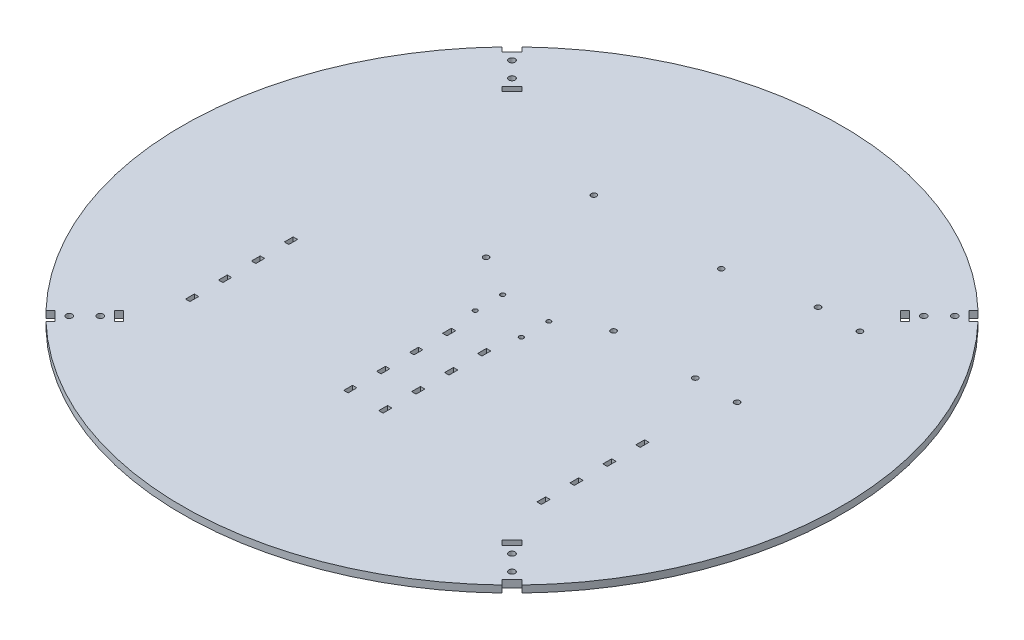
from build123d import *

# Parameters (mm, degrees)
SKETCH1_R           = 150
SKETCH1_R_2         = 1.25
SKETCH1_R_3         = 1
SKETCH1_W           = 2
SKETCH1_H           = 4
BOSS_EXTRUDE1_DEPTH = 3.175
SKETCH2_R           = 1.4224
CUT_EXTRUDE1_DEPTH  = 10


with BuildPart() as part:
    # Sketch1 → Boss-Extrude1 (new body)
    with BuildSketch(Plane(origin=(0, 0, 0), x_dir=(1, 0, 0), z_dir=(0, 1, 0))):
        with Locations((106.066017178, 106.066017178)):
            Circle(SKETCH1_R)
        with Locations((77.066017178, 172.293864025)):
            Circle(SKETCH1_R_2, mode=Mode.SUBTRACT)
        with Locations((135.066017178, 172.293864025)):
            Circle(SKETCH1_R_2, mode=Mode.SUBTRACT)
        with Locations((77.066017178, 123.293864025)):
            Circle(SKETCH1_R_2, mode=Mode.SUBTRACT)
        with Locations((135.066017178, 123.293864025)):
            Circle(SKETCH1_R_2, mode=Mode.SUBTRACT)
        with Locations((95.566017178, 112.316017178)):
            Circle(SKETCH1_R_3, mode=Mode.SUBTRACT)
        with Locations((116.566017178, 112.316017178)):
            Circle(SKETCH1_R_3, mode=Mode.SUBTRACT)
        with Locations((116.566017178, 99.816017178)):
            Circle(SKETCH1_R_3, mode=Mode.SUBTRACT)
        with Locations((95.566017178, 99.816017178)):
            Circle(SKETCH1_R_3, mode=Mode.SUBTRACT)
        with Locations((172.245046965, 123.293864025)):
            Circle(SKETCH1_R_2, mode=Mode.SUBTRACT)
        with Locations((172.245046965, 179.173864025)):
            Circle(SKETCH1_R_2, mode=Mode.SUBTRACT)
        with Locations((191.295046965, 123.293864025)):
            Circle(SKETCH1_R_2, mode=Mode.SUBTRACT)
        with Locations((191.295046965, 179.173864025)):
            Circle(SKETCH1_R_2, mode=Mode.SUBTRACT)
        with Locations((98.098528615, 85.439926251)):
            Rectangle(SKETCH1_W, SKETCH1_H, mode=Mode.SUBTRACT)
        with Locations((26.098528615, 85.439926251)):
            Rectangle(SKETCH1_W, SKETCH1_H, mode=Mode.SUBTRACT)
        with Locations((98.098528615, 70.439926251)):
            Rectangle(SKETCH1_W, SKETCH1_H, mode=Mode.SUBTRACT)
        with Locations((98.098528615, 55.439926251)):
            Rectangle(SKETCH1_W, SKETCH1_H, mode=Mode.SUBTRACT)
        with Locations((98.098528615, 40.439926251)):
            Rectangle(SKETCH1_W, SKETCH1_H, mode=Mode.SUBTRACT)
        with Locations((26.098528615, 70.439926251)):
            Rectangle(SKETCH1_W, SKETCH1_H, mode=Mode.SUBTRACT)
        with Locations((26.098528615, 55.439926251)):
            Rectangle(SKETCH1_W, SKETCH1_H, mode=Mode.SUBTRACT)
        with Locations((26.098528615, 40.439926251)):
            Rectangle(SKETCH1_W, SKETCH1_H, mode=Mode.SUBTRACT)
        with Locations((114.033505741, 85.439926251)):
            Rectangle(SKETCH1_W, SKETCH1_H, mode=Mode.SUBTRACT)
        with Locations((114.033505741, 70.439926251)):
            Rectangle(SKETCH1_W, SKETCH1_H, mode=Mode.SUBTRACT)
        with Locations((114.033505741, 55.439926251)):
            Rectangle(SKETCH1_W, SKETCH1_H, mode=Mode.SUBTRACT)
        with Locations((114.033505741, 40.439926251)):
            Rectangle(SKETCH1_W, SKETCH1_H, mode=Mode.SUBTRACT)
        with Locations((186.033505741, 40.439926251)):
            Rectangle(SKETCH1_W, SKETCH1_H, mode=Mode.SUBTRACT)
        with Locations((186.033505741, 55.439926251)):
            Rectangle(SKETCH1_W, SKETCH1_H, mode=Mode.SUBTRACT)
        with Locations((186.033505741, 70.439926251)):
            Rectangle(SKETCH1_W, SKETCH1_H, mode=Mode.SUBTRACT)
        with Locations((186.033505741, 85.439926251)):
            Rectangle(SKETCH1_W, SKETCH1_H, mode=Mode.SUBTRACT)
    extrude(amount=BOSS_EXTRUDE1_DEPTH)

    # Sketch2 → Cut-Extrude1 (cut)
    with BuildSketch(Plane(origin=(0, 3.175, 0), x_dir=(1, 0, 0), z_dir=(0, 1, 0))):
        with Locations((5.303300859, 206.828733497)):
            Circle(SKETCH2_R)
        with Locations((12.374368671, 199.757665685)):
            Circle(SKETCH2_R)
        with Locations((206.828733497, 206.828733497)):
            Circle(SKETCH2_R)
        with Locations((199.757665685, 199.757665685)):
            Circle(SKETCH2_R)
        with Locations((206.828733497, 5.303300859)):
            Circle(SKETCH2_R)
        with Locations((199.757665685, 12.374368671)):
            Circle(SKETCH2_R)
        with Locations((5.303300859, 5.303300859)):
            Circle(SKETCH2_R)
        with Locations((12.374368671, 12.374368671)):
            Circle(SKETCH2_R)
        Polygon((15.432605499, 192.209300796), (13.311285156, 194.33062114), (17.801413216, 198.8207492), (19.92273356, 196.699428857), align=None)
        Polygon((-0.123743687, 207.765649982), (-2.24506403, 209.886970326), (2.24506403, 214.377098386), (4.366384374, 212.255778043), align=None)
        Polygon((192.209300796, 196.699428857), (194.33062114, 198.8207492), (198.8207492, 194.33062114), (196.699428857, 192.209300796), align=None)
        Polygon((207.765649982, 212.255778043), (209.886970326, 214.377098386), (214.377098386, 209.886970326), (212.255778043, 207.765649982), align=None)
        Polygon((196.699428857, 19.92273356), (198.8207492, 17.801413216), (194.33062114, 13.311285156), (192.209300796, 15.432605499), align=None)
        Polygon((212.255778043, 4.366384374), (214.377098386, 2.24506403), (209.886970326, -2.24506403), (207.765649982, -0.123743687), align=None)
        Polygon((19.92273356, 15.432605499), (17.801413216, 13.311285156), (13.311285156, 17.801413216), (15.432605499, 19.92273356), align=None)
        Polygon((4.366384374, -0.123743687), (2.24506403, -2.24506403), (-2.24506403, 2.24506403), (-0.123743687, 4.366384374), align=None)
    extrude(amount=-CUT_EXTRUDE1_DEPTH, mode=Mode.SUBTRACT)


solid = part.part
